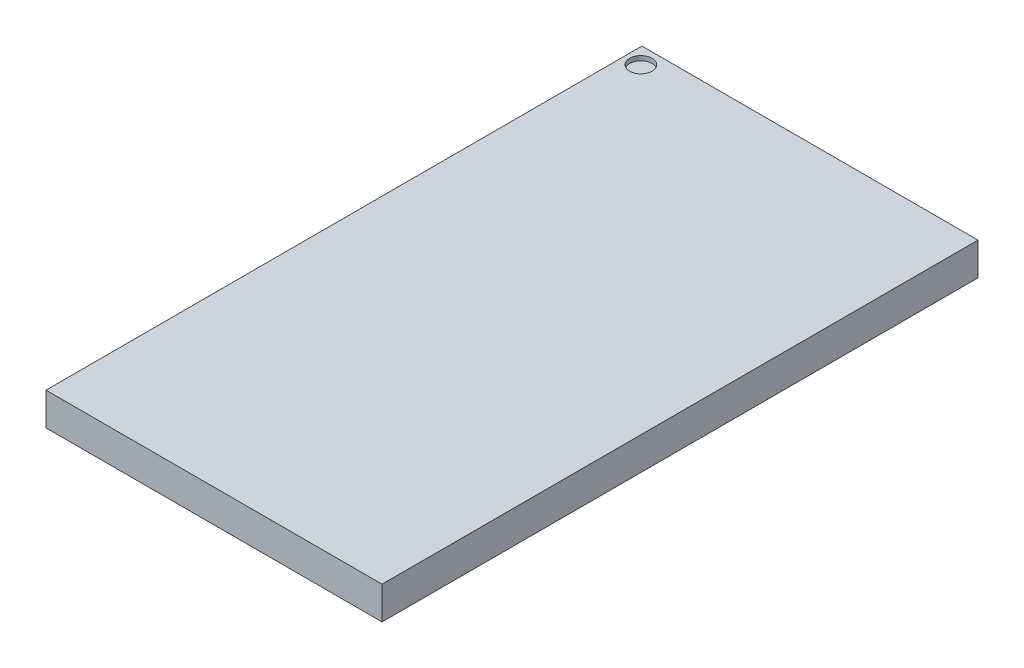
from build123d import *

# Parameters (mm, degrees)
SKETCH1_W           = 7.5
SKETCH1_H           = 13.3
BOSS_EXTRUDE1_DEPTH = 0.73
SKETCH2_R           = 0.25
CUT_EXTRUDE1_DEPTH  = 0.1
SKETCH3_R           = 0.2
BOSS_EXTRUDE2_DEPTH = 0.3
FILLET1_R           = 0.15


with BuildPart() as part:
    # Sketch1 → Boss-Extrude1 (new body)
    with BuildSketch(Plane(origin=(0, 0, 0), x_dir=(1, 0, 0), z_dir=(0, 1, 0))):
        Rectangle(SKETCH1_W, SKETCH1_H)
    extrude(amount=BOSS_EXTRUDE1_DEPTH)

    # Sketch2 → Cut-Extrude1 (cut)
    with BuildSketch(Plane(origin=(0, 0.73, 0), x_dir=(1, 0, 0), z_dir=(0, 1, 0))):
        with Locations((-3.400950327, 6.277375977)):
            Circle(SKETCH2_R)
    extrude(amount=-CUT_EXTRUDE1_DEPTH, mode=Mode.SUBTRACT)

    # Sketch3 → Boss-Extrude2 (add)
    with BuildSketch(Plane.XZ):
        with Locations((-3.195, 6)):
            Circle(SKETCH3_R)
        with Locations((-2.395, 6)):
            Circle(SKETCH3_R)
        with Locations((-1.595, 6)):
            Circle(SKETCH3_R)
        with Locations((-2.395, 5.2)):
            Circle(SKETCH3_R)
        with Locations((-1.595, 5.2)):
            Circle(SKETCH3_R)
        with Locations((-2.395, 4.4)):
            Circle(SKETCH3_R)
        with Locations((-1.595, 4.4)):
            Circle(SKETCH3_R)
        with Locations((-2.395, 3.6)):
            Circle(SKETCH3_R)
        with Locations((-1.595, 3.6)):
            Circle(SKETCH3_R)
        with Locations((-2.395, 2.8)):
            Circle(SKETCH3_R)
        with Locations((-1.595, 2.8)):
            Circle(SKETCH3_R)
        with Locations((-2.395, 2)):
            Circle(SKETCH3_R)
        with Locations((-1.595, 2)):
            Circle(SKETCH3_R)
        with Locations((-2.395, 1.2)):
            Circle(SKETCH3_R)
        with Locations((-1.595, 1.2)):
            Circle(SKETCH3_R)
        with Locations((-2.395, 0.4)):
            Circle(SKETCH3_R)
        with Locations((-1.595, 0.4)):
            Circle(SKETCH3_R)
        with Locations((-2.395, -0.4)):
            Circle(SKETCH3_R)
        with Locations((-1.595, -0.4)):
            Circle(SKETCH3_R)
        with Locations((-2.395, -1.2)):
            Circle(SKETCH3_R)
        with Locations((-1.595, -1.2)):
            Circle(SKETCH3_R)
        with Locations((-2.395, -2)):
            Circle(SKETCH3_R)
        with Locations((-1.595, -2)):
            Circle(SKETCH3_R)
        with Locations((-2.395, -2.8)):
            Circle(SKETCH3_R)
        with Locations((-1.595, -2.8)):
            Circle(SKETCH3_R)
        with Locations((-2.395, -3.6)):
            Circle(SKETCH3_R)
        with Locations((-1.595, -3.6)):
            Circle(SKETCH3_R)
        with Locations((-2.395, -4.4)):
            Circle(SKETCH3_R)
        with Locations((-1.595, -4.4)):
            Circle(SKETCH3_R)
        with Locations((-2.395, -5.2)):
            Circle(SKETCH3_R)
        with Locations((-1.595, -5.2)):
            Circle(SKETCH3_R)
        with Locations((-2.395, -6)):
            Circle(SKETCH3_R)
        with Locations((-1.595, -6)):
            Circle(SKETCH3_R)
        with Locations((-3.195, 5.2)):
            Circle(SKETCH3_R)
        with Locations((-3.195, 4.4)):
            Circle(SKETCH3_R)
        with Locations((-3.195, 3.6)):
            Circle(SKETCH3_R)
        with Locations((-3.195, 2.8)):
            Circle(SKETCH3_R)
        with Locations((-3.195, 2)):
            Circle(SKETCH3_R)
        with Locations((-3.195, 1.2)):
            Circle(SKETCH3_R)
        with Locations((-3.195, 0.4)):
            Circle(SKETCH3_R)
        with Locations((-3.195, -0.4)):
            Circle(SKETCH3_R)
        with Locations((-3.195, -1.2)):
            Circle(SKETCH3_R)
        with Locations((-3.195, -2)):
            Circle(SKETCH3_R)
        with Locations((-3.195, -2.8)):
            Circle(SKETCH3_R)
        with Locations((-3.195, -3.6)):
            Circle(SKETCH3_R)
        with Locations((-3.195, -4.4)):
            Circle(SKETCH3_R)
        with Locations((-3.195, -5.2)):
            Circle(SKETCH3_R)
        with Locations((-3.195, -6)):
            Circle(SKETCH3_R)
        with Locations((3.195, -6)):
            Circle(SKETCH3_R)
        with Locations((3.195, -5.2)):
            Circle(SKETCH3_R)
        with Locations((3.195, -4.4)):
            Circle(SKETCH3_R)
        with Locations((3.195, -3.6)):
            Circle(SKETCH3_R)
        with Locations((3.195, -2.8)):
            Circle(SKETCH3_R)
        with Locations((3.195, -2)):
            Circle(SKETCH3_R)
        with Locations((3.195, -1.2)):
            Circle(SKETCH3_R)
        with Locations((3.195, -0.4)):
            Circle(SKETCH3_R)
        with Locations((3.195, 0.4)):
            Circle(SKETCH3_R)
        with Locations((3.195, 1.2)):
            Circle(SKETCH3_R)
        with Locations((3.195, 2)):
            Circle(SKETCH3_R)
        with Locations((3.195, 2.8)):
            Circle(SKETCH3_R)
        with Locations((3.195, 3.6)):
            Circle(SKETCH3_R)
        with Locations((3.195, 4.4)):
            Circle(SKETCH3_R)
        with Locations((3.195, 5.2)):
            Circle(SKETCH3_R)
        with Locations((1.595, -6)):
            Circle(SKETCH3_R)
        with Locations((2.395, -6)):
            Circle(SKETCH3_R)
        with Locations((1.595, -5.2)):
            Circle(SKETCH3_R)
        with Locations((2.395, -5.2)):
            Circle(SKETCH3_R)
        with Locations((1.595, -4.4)):
            Circle(SKETCH3_R)
        with Locations((2.395, -4.4)):
            Circle(SKETCH3_R)
        with Locations((1.595, -3.6)):
            Circle(SKETCH3_R)
        with Locations((2.395, -3.6)):
            Circle(SKETCH3_R)
        with Locations((1.595, -2.8)):
            Circle(SKETCH3_R)
        with Locations((2.395, -2.8)):
            Circle(SKETCH3_R)
        with Locations((1.595, -2)):
            Circle(SKETCH3_R)
        with Locations((2.395, -2)):
            Circle(SKETCH3_R)
        with Locations((1.595, -1.2)):
            Circle(SKETCH3_R)
        with Locations((2.395, -1.2)):
            Circle(SKETCH3_R)
        with Locations((1.595, -0.4)):
            Circle(SKETCH3_R)
        with Locations((2.395, -0.4)):
            Circle(SKETCH3_R)
        with Locations((1.595, 0.4)):
            Circle(SKETCH3_R)
        with Locations((2.395, 0.4)):
            Circle(SKETCH3_R)
        with Locations((1.595, 1.2)):
            Circle(SKETCH3_R)
        with Locations((2.395, 1.2)):
            Circle(SKETCH3_R)
        with Locations((1.595, 2)):
            Circle(SKETCH3_R)
        with Locations((2.395, 2)):
            Circle(SKETCH3_R)
        with Locations((1.595, 2.8)):
            Circle(SKETCH3_R)
        with Locations((2.395, 2.8)):
            Circle(SKETCH3_R)
        with Locations((1.595, 3.6)):
            Circle(SKETCH3_R)
        with Locations((2.395, 3.6)):
            Circle(SKETCH3_R)
        with Locations((1.595, 4.4)):
            Circle(SKETCH3_R)
        with Locations((2.395, 4.4)):
            Circle(SKETCH3_R)
        with Locations((1.595, 5.2)):
            Circle(SKETCH3_R)
        with Locations((2.395, 5.2)):
            Circle(SKETCH3_R)
        with Locations((1.595, 6)):
            Circle(SKETCH3_R)
        with Locations((2.395, 6)):
            Circle(SKETCH3_R)
        with Locations((3.195, 6)):
            Circle(SKETCH3_R)
    extrude(amount=BOSS_EXTRUDE2_DEPTH)

    # Fillet1
    fillet1_edges = [part.edges().sort_by_distance(p)[0] for p in [
        (-2.595, -0.3, -3.6),
        (-1.795, -0.3, -3.6),
        (-2.595, -0.3, -4.4),
        (-1.795, -0.3, -4.4),
        (-2.595, -0.3, -5.2),
        (-1.795, -0.3, -5.2),
        (-2.595, -0.3, -6),
        (-1.795, -0.3, -6),
        (-3.395, -0.3, 5.2),
        (-3.395, -0.3, 4.4),
        (-3.395, -0.3, 3.6),
        (-3.395, -0.3, 2.8),
        (-3.395, -0.3, 2),
        (-3.395, -0.3, 1.2),
        (-3.395, -0.3, 0.4),
        (-3.395, -0.3, -0.4),
        (-3.395, -0.3, -1.2),
        (-3.395, -0.3, -2),
        (-3.395, -0.3, -2.8),
        (-3.395, -0.3, -3.6),
        (-3.395, -0.3, -4.4),
        (-3.395, -0.3, -5.2),
        (-3.395, -0.3, -6),
        (2.995, -0.3, -6),
        (2.995, -0.3, -5.2),
        (2.995, -0.3, -4.4),
        (2.995, -0.3, -3.6),
        (2.995, -0.3, -2.8),
        (2.995, -0.3, -2),
        (-3.395, -0.3, 6),
        (2.995, -0.3, -1.2),
        (2.995, -0.3, -0.4),
        (2.995, -0.3, 0.4),
        (2.995, -0.3, 1.2),
        (2.995, -0.3, 2),
        (2.995, -0.3, 2.8),
        (2.995, -0.3, 3.6),
        (2.995, -0.3, 4.4),
        (2.995, -0.3, 5.2),
        (1.395, -0.3, -6),
        (-2.595, -0.3, 6),
        (2.195, -0.3, -6),
        (1.395, -0.3, -5.2),
        (2.195, -0.3, -5.2),
        (1.395, -0.3, -4.4),
        (2.195, -0.3, -4.4),
        (1.395, -0.3, -3.6),
        (2.195, -0.3, -3.6),
        (1.395, -0.3, -2.8),
        (2.195, -0.3, -2.8),
        (1.395, -0.3, -2),
        (-1.795, -0.3, 6),
        (2.195, -0.3, -2),
        (1.395, -0.3, -1.2),
        (2.195, -0.3, -1.2),
        (1.395, -0.3, -0.4),
        (2.195, -0.3, -0.4),
        (1.395, -0.3, 0.4),
        (2.195, -0.3, 0.4),
        (1.395, -0.3, 1.2),
        (2.195, -0.3, 1.2),
        (1.395, -0.3, 2),
        (-2.595, -0.3, 5.2),
        (2.195, -0.3, 2),
        (1.395, -0.3, 2.8),
        (2.195, -0.3, 2.8),
        (1.395, -0.3, 3.6),
        (2.195, -0.3, 3.6),
        (1.395, -0.3, 4.4),
        (2.195, -0.3, 4.4),
        (1.395, -0.3, 5.2),
        (2.195, -0.3, 5.2),
        (1.395, -0.3, 6),
        (-1.795, -0.3, 5.2),
        (2.195, -0.3, 6),
        (2.995, -0.3, 6),
        (-2.595, -0.3, 4.4),
        (-1.795, -0.3, 4.4),
        (-2.595, -0.3, 3.6),
        (-1.795, -0.3, 3.6),
        (-2.595, -0.3, 2.8),
        (-1.795, -0.3, 2.8),
        (-2.595, -0.3, 2),
        (-1.795, -0.3, 2),
        (-2.595, -0.3, 1.2),
        (-1.795, -0.3, 1.2),
        (-2.595, -0.3, 0.4),
        (-1.795, -0.3, 0.4),
        (-2.595, -0.3, -0.4),
        (-1.795, -0.3, -0.4),
        (-2.595, -0.3, -1.2),
        (-1.795, -0.3, -1.2),
        (-2.595, -0.3, -2),
        (-1.795, -0.3, -2),
        (-2.595, -0.3, -2.8),
        (-1.795, -0.3, -2.8),
    ]]
    fillet(fillet1_edges, radius=FILLET1_R)


solid = part.part
